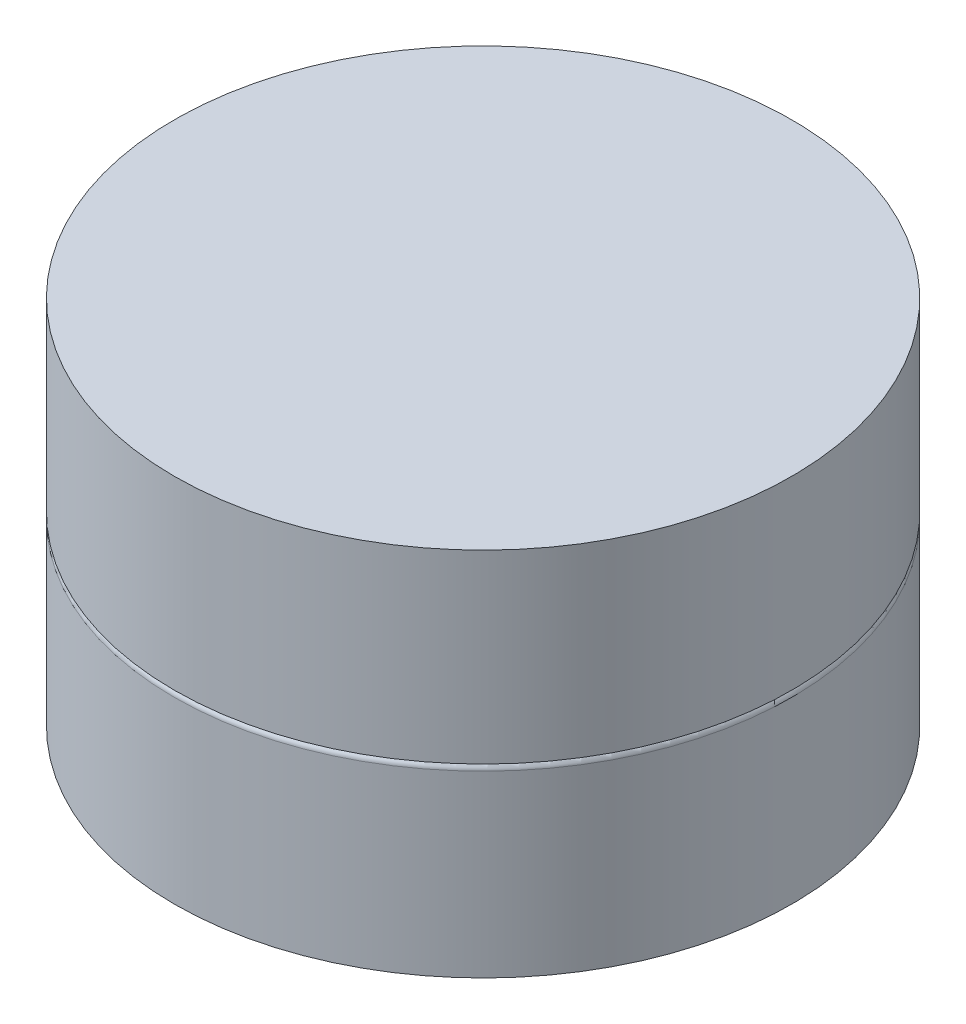
from build123d import *

# Parameters (mm, degrees)
SKETCH1_R           = 2.5
BOSS_EXTRUDE1_DEPTH = 1.5
FILLET1_R           = 0.05
SKETCH2_R           = 2.5
BOSS_EXTRUDE2_DEPTH = 1.5


with BuildPart() as part:
    # Sketch1 → Boss-Extrude1 (new body)
    with BuildSketch(Plane(origin=(0, 0, 0), x_dir=(1, 0, 0), z_dir=(0, 1, 0))):
        Circle(SKETCH1_R)
    extrude(amount=BOSS_EXTRUDE1_DEPTH)

    # Fillet1
    fillet1_edges = [part.edges().sort_by_distance(p)[0] for p in [
        (-2.5, 1.5, 0),
    ]]
    fillet(fillet1_edges, radius=FILLET1_R)

    # Sketch2 → Boss-Extrude2 (add)
    with BuildSketch(Plane(origin=(0, 1.5, 0), x_dir=(1, 0, 0), z_dir=(0, 1, 0))):
        Circle(SKETCH2_R)
    extrude(amount=BOSS_EXTRUDE2_DEPTH)


solid = part.part
